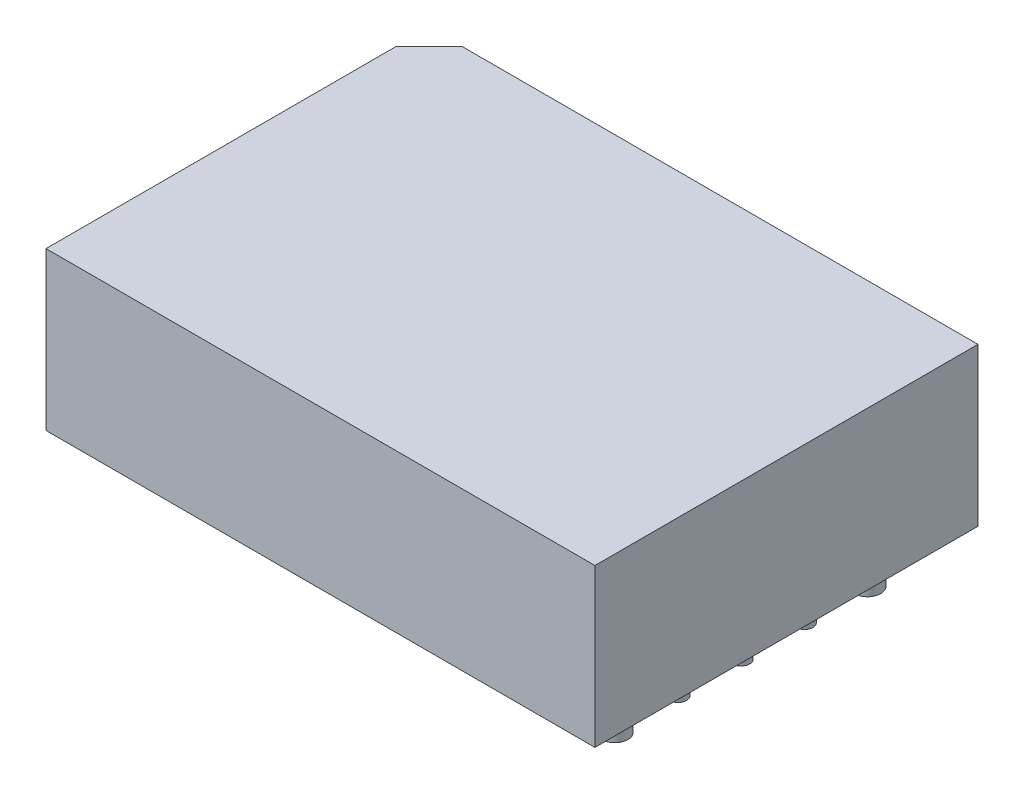
from build123d import *

# Parameters (mm, degrees)
BOSS_EXTRUDE1_DEPTH = 9.5
SKETCH4_R           = 0.785
SKETCH4_R_2         = 0.51
BOSS_EXTRUDE2_DEPTH = 12


with BuildPart() as part:
    # Sketch1 → Boss-Extrude1 (new body)
    with BuildSketch(Plane(origin=(0, 0, 0), x_dir=(1, 0, 0), z_dir=(0, 1, 0))):
        Polygon((-31.1, 23.1), (-33.1, 21.1), (-33.1, 0), (0, 0), (0, 23.1), align=None)
    extrude(amount=BOSS_EXTRUDE1_DEPTH)

    # Sketch4 → Boss-Extrude2 (add)
    with BuildSketch(Plane(origin=(0, 9.5, 0), x_dir=(1, 0, 0), z_dir=(0, 1, 0))):
        with Locations(Location((-2.7, 19.14, 0), (0, 0, 270))):
            Circle(SKETCH4_R)
        with Locations((-2.7, 19.14)):
            Circle(SKETCH4_R_2, mode=Mode.SUBTRACT)
        with Locations((-2.7, 19.14)):
            Circle(SKETCH4_R_2)
        with Locations(Location((-2.7, 15.33, 0), (0, 0, 270))):
            Circle(SKETCH4_R_2)
        with Locations(Location((-2.7, 3.9, 0), (0, 0, 270))):
            Circle(SKETCH4_R)
        with Locations((-2.7, 3.9)):
            Circle(SKETCH4_R_2, mode=Mode.SUBTRACT)
        with Locations((-2.7, 3.9)):
            Circle(SKETCH4_R_2)
        with Locations(Location((-2.7, 7.71, 0), (0, 0, 270))):
            Circle(SKETCH4_R_2)
        with Locations(Location((-2.7, 11.52, 0), (0, 0, 270))):
            Circle(SKETCH4_R_2)
        with Locations(Location((-30.64, 3.9, 0), (0, 0, 270))):
            Circle(SKETCH4_R_2)
        with Locations(Location((-30.64, 19.14, 0), (0, 0, 270))):
            Circle(SKETCH4_R_2)
        with Locations(Location((-30.64, 11.52, 0), (0, 0, 270))):
            Circle(SKETCH4_R_2)
    extrude(amount=-BOSS_EXTRUDE2_DEPTH)


solid = part.part
